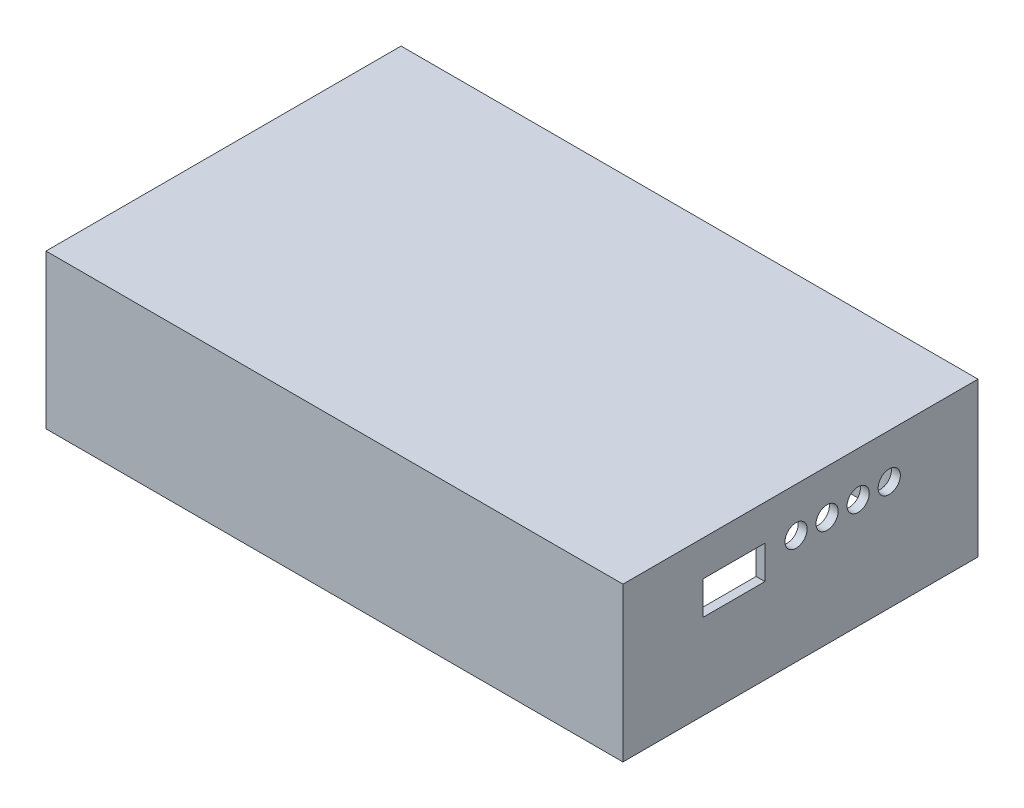
from build123d import *

# Parameters (mm, degrees)
ESQUISSE1_W             = 130
ESQUISSE1_H             = 80
BOSS_EXTRU_1_DEPTH      = 2
ESQUISSE2_W             = 130
ESQUISSE2_H             = 80
ESQUISSE2_R             = 5.1
BOSS_EXTRU_2_DEPTH      = 32.7
ESQUISSE3_R             = 2.5
ESQUISSE3_W             = 14
ESQUISSE3_H             = 7.5
ENL_V_MAT_EXTRU_1_DEPTH = 10
ESQUISSE4_R             = 5.5
BOSS_EXTRU_3_DEPTH      = 29.5


with BuildPart() as part:
    # Esquisse1 → Boss.-Extru.1 (new body)
    with BuildSketch(Plane(origin=(0, 0, 0), x_dir=(1, 0, 0), z_dir=(0, 1, 0))):
        with Locations((65, 40)):
            Rectangle(ESQUISSE1_W, ESQUISSE1_H)
    extrude(amount=BOSS_EXTRU_1_DEPTH)

    # Esquisse2 → Boss.-Extru.2 (add)
    with BuildSketch(Plane.XZ):
        with Locations((65, -40)):
            Rectangle(ESQUISSE2_W, ESQUISSE2_H)
        with Locations((123, -7)):
            Circle(ESQUISSE2_R, mode=Mode.SUBTRACT)
        with Locations((123, -73)):
            Circle(ESQUISSE2_R, mode=Mode.SUBTRACT)
        with Locations((7, -7)):
            Circle(ESQUISSE2_R, mode=Mode.SUBTRACT)
        with Locations((7, -73)):
            Circle(ESQUISSE2_R, mode=Mode.SUBTRACT)
        with BuildLine():
            Line((11.898979486, -78), (118.101020514, -78))
            ThreePointArc((118.101020514, -78), (118.050252532, -68.050252532), (128, -68.101020514))
            Line((128, -68.101020514), (128, -11.898979486))
            ThreePointArc((128, -11.898979486), (118.050252532, -11.949747468), (118.101020514, -2))
            Line((118.101020514, -2), (11.898979486, -2))
            ThreePointArc((11.898979486, -2), (11.949747468, -11.949747468), (2, -11.898979486))
            Line((2, -11.898979486), (2, -68.101020514))
            ThreePointArc((2, -68.101020514), (11.949747468, -68.050252532), (11.898979486, -78))
        make_face(mode=Mode.SUBTRACT)
    extrude(amount=BOSS_EXTRU_2_DEPTH)

    # Esquisse3 → Enlèv. mat.-Extru.1 (cut)
    with BuildSketch(Plane(origin=(130, 0, 0), x_dir=(0, 0, -1), z_dir=(1, 0, 0))):
        with Locations((39, -8)):
            Circle(ESQUISSE3_R)
        with Locations((46, -8)):
            Circle(ESQUISSE3_R)
        with Locations((53, -8)):
            Circle(ESQUISSE3_R)
        with Locations((60, -8)):
            Circle(ESQUISSE3_R)
        with Locations((25, -9.75)):
            Rectangle(ESQUISSE3_W, ESQUISSE3_H)
    extrude(amount=-ENL_V_MAT_EXTRU_1_DEPTH, mode=Mode.SUBTRACT)

    # Esquisse4 → Boss.-Extru.3 (add)
    with BuildSketch(Plane.XZ):
        with Locations((7, -7)):
            Circle(ESQUISSE4_R)
        with Locations((123, -7)):
            Circle(ESQUISSE4_R)
        with Locations((123, -73)):
            Circle(ESQUISSE4_R)
        with Locations((7, -73)):
            Circle(ESQUISSE4_R)
    extrude(amount=BOSS_EXTRU_3_DEPTH)


solid = part.part
